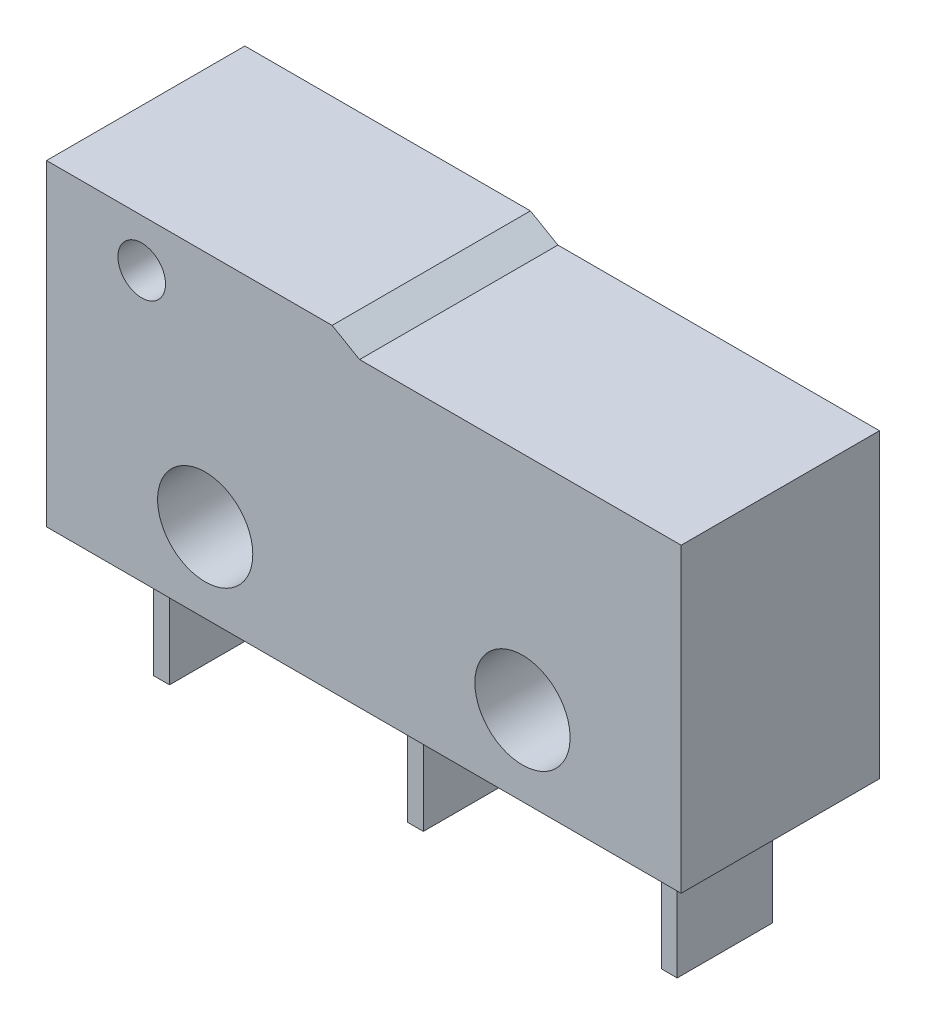
from build123d import *

# Parameters (mm, degrees)
SKETCH1_R           = 1.5
SKETCH1_R_2         = 0.75
BOSS_EXTRUDE1_DEPTH = 3.125
SKETCH2_W           = 0.5
SKETCH2_H           = 3
BOSS_EXTRUDE2_DEPTH = 4


with BuildPart() as part:
    # Sketch1 → Boss-Extrude1 (new body, symmetric)
    with BuildSketch(Plane.XY):
        Polygon((10, 0), (-10, 0), (-10, 10), (-1, 10), (-0.133974596, 9.5), (10, 9.5), align=None)
        with Locations((-5, 2.5)):
            Circle(SKETCH1_R, mode=Mode.SUBTRACT)
        with Locations((5, 2.5)):
            Circle(SKETCH1_R, mode=Mode.SUBTRACT)
        with Locations((-7, 8.5)):
            Circle(SKETCH1_R_2, mode=Mode.SUBTRACT)
    extrude(amount=BOSS_EXTRUDE1_DEPTH, both=True)

    # Sketch2 → Boss-Extrude2 (add)
    with BuildSketch(Plane.XZ):
        Rectangle(SKETCH2_W, SKETCH2_H)
        with Locations((-8, 0)):
            Rectangle(SKETCH2_W, SKETCH2_H)
        with Locations((8, 0)):
            Rectangle(SKETCH2_W, SKETCH2_H)
    extrude(amount=BOSS_EXTRUDE2_DEPTH)


solid = part.part
